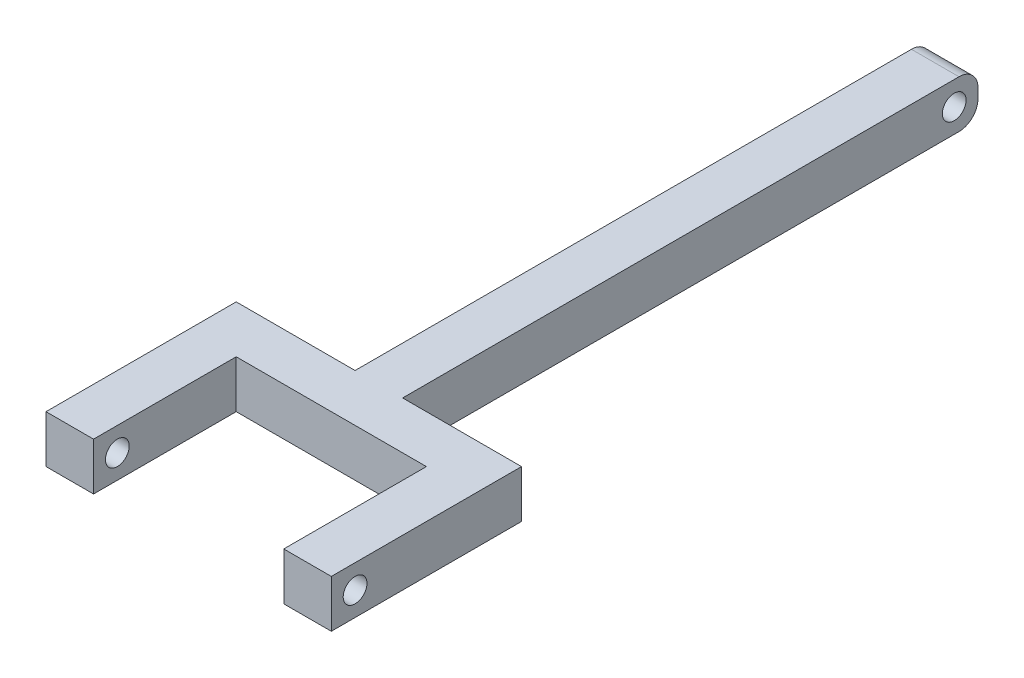
from build123d import *

# Parameters (mm, degrees)
SKETCH1_W                = 12.7
SKETCH1_H                = 12.7
BOSS_EXTRUDE1_DEPTH      = 86.36
BOSS_EXTRUDE1_DEPTH_BACK = 80.01
SKETCH4_W                = 12.7
SKETCH4_H                = 12.7
BOSS_EXTRUDE2_DEPTH      = 38.1
SKETCH5_W                = 12.7
SKETCH5_H                = 12.7
BOSS_EXTRUDE3_DEPTH      = 50.8
SKETCH6_R                = 3.175
CUT_EXTRUDE1_DEPTH       = 16.51
SKETCH7_R                = 3.175
CUT_EXTRUDE2_DEPTH       = 45.45
FILLET1_R                = 5.08


with BuildPart() as part:
    # Sketch1 → Boss-Extrude1 (new body, two sides)
    with BuildSketch(Plane.XY) as boss_extrude1_sk:
        Rectangle(SKETCH1_W, SKETCH1_H)
    extrude(amount=BOSS_EXTRUDE1_DEPTH)
    extrude(boss_extrude1_sk.sketch, amount=-BOSS_EXTRUDE1_DEPTH_BACK)

    # Sketch4 → Boss-Extrude2 (add, symmetric)
    with BuildSketch(Plane(origin=(0, 0, 0), x_dir=(0, 0, -1), z_dir=(1, 0, 0))):
        with Locations((-80.01, 0)):
            Rectangle(SKETCH4_W, SKETCH4_H)
    extrude(amount=BOSS_EXTRUDE2_DEPTH, both=True)

    # Sketch5 → Boss-Extrude3 (add)
    with BuildSketch(Plane(origin=(0, 0, 73.66), x_dir=(-1, 0, 0), z_dir=(0, 0, -1))):
        with Locations((-31.75, 0)):
            Rectangle(SKETCH5_W, SKETCH5_H)
    boss_extrude3 = extrude(amount=-BOSS_EXTRUDE3_DEPTH)

    # Sketch6 → Cut-Extrude1 (cut)
    with BuildSketch(Plane.ZY.offset(-25.4)):
        with Locations((118.11, 0)):
            Circle(SKETCH6_R)
    cut_extrude1 = extrude(amount=-CUT_EXTRUDE1_DEPTH, mode=Mode.SUBTRACT)

    # Mirror1: Boss-Extrude3, Cut-Extrude1 across plane
    add(boss_extrude3.mirror(Plane(origin=(0, 0, 0), x_dir=(0, 0, 1), z_dir=(1, 0, 0))))
    add(cut_extrude1.mirror(Plane(origin=(0, 0, 0), x_dir=(0, 0, 1), z_dir=(1, 0, 0))), mode=Mode.SUBTRACT)

    # Sketch7 → Cut-Extrude2 (cut, through all)
    with BuildSketch(Plane.ZY.offset(6.35)):
        with Locations((-73.66, 0)):
            Circle(SKETCH7_R)
    extrude(amount=-CUT_EXTRUDE2_DEPTH, mode=Mode.SUBTRACT)

    # Fillet1
    fillet1_edges = [part.edges().sort_by_distance(p)[0] for p in [
        (0, 6.35, -80.01),
        (0, -6.35, -80.01),
    ]]
    fillet(fillet1_edges, radius=FILLET1_R)


solid = part.part
